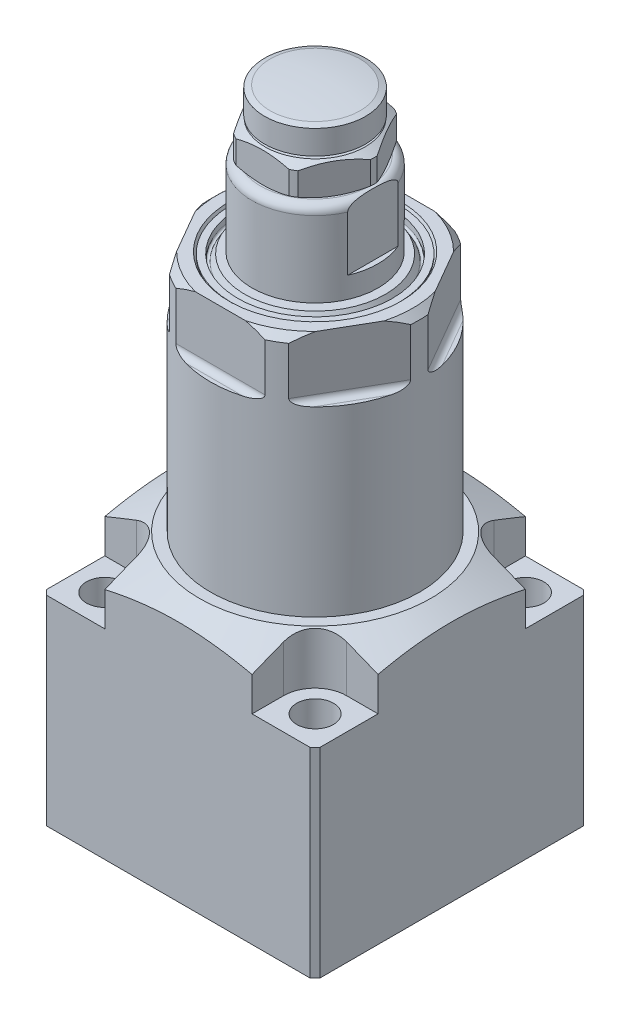
from build123d import *

# Parameters (mm, degrees)
SKETCH2_OUTSIDE_W   = 48.332
SKETCH2_OUTSIDE_H   = 48.332
CUT_EXTRUDE1_DEPTH  = 9.144
FILLET1_R           = 0.9144
SKETCH4_W           = 0.79375
SKETCH4_H           = 9.525
CUT_EXTRUDE2_DEPTH  = 11.1125
SKETCH5_W           = 4.6736
SKETCH5_H           = 6.35
SKETCH8_OUTSIDE_W   = 51.238
SKETCH8_OUTSIDE_H   = 51.238
CUT_EXTRUDE3_DEPTH  = 4.7752
SKETCH9_W           = 41.275
SKETCH9_H           = 38.1
BOSS_EXTRUDE1_DEPTH = 20.6375
CHAMFER1_SIZE       = 0.762
SKETCH10_R          = 2.7813
CUT_EXTRUDE4_DEPTH  = 41.275
SKETCH12_R          = 10.4775
CUT_EXTRUDE5_DEPTH  = 0.254
SKETCH13_R          = 4.9784
CUT_EXTRUDE6_DEPTH  = 8.89
SKETCH14_R          = 4.3688
CUT_EXTRUDE7_DEPTH  = 8.89
SKETCH15_R          = 6.4135
CUT_EXTRUDE8_DEPTH  = 1.9558
SKETCH16_R          = 4.1656
CUT_EXTRUDE9_DEPTH  = 3.9624
CUT_EXTRUDE10_DEPTH = 6.35
CUT_EXTRUDE11_DEPTH = 7.9375


with BuildPart() as part:
    # Sketch1 → Revolve1 (revolve)
    with BuildSketch(Plane.XY):
        with BuildLine():
            Line((9.4615, 0), (10.5918, 0))
            Line((10.5918, 0), (10.9728, 0.381))
            Line((10.9728, 0.381), (14.1097, 0.381))
            Line((14.1097, 0.381), (14.8717, 1.143))
            Line((14.8717, 1.143), (14.8717, 8.3058))
            Line((14.8717, 8.3058), (15.7988, 9.2329))
            Line((15.7988, 9.2329), (15.7988, 57.0992))
            Line((15.7988, 57.0992), (14.7828, 58.1152))
            Line((14.7828, 58.1152), (12.993293937, 58.1152))
            Line((12.993293937, 58.1152), (12.7, 57.6072))
            Line((12.7, 57.6072), (12.7, 57.8358))
            Line((12.7, 57.8358), (11.684, 57.8358))
            Line((11.684, 57.8358), (11.684, 56.9468))
            ThreePointArc((11.684, 56.9468), (11.495740037, 56.70145484), (11.210029547, 56.8198))
            Line((11.210029547, 56.8198), (10.623441674, 57.8358))
            Line((10.623441674, 57.8358), (0, 57.8358))
            Line((0, 57.8358), (0, 5.1308))
            Line((0, 5.1308), (2.3876, 5.1308))
            Line((2.3876, 5.1308), (2.3876, 1.3208))
            Line((2.3876, 1.3208), (8.5725, 1.3208))
            ThreePointArc((8.5725, 1.3208), (7.943882072, -0.196817928), (9.4615, 0.4318))
            Line((9.4615, 0.4318), (9.4615, 0))
        make_face()
    revolve(axis=Axis((0, 0, 0), (0, 1, 0)))

    # Sketch2 outside → Cut-Extrude1 (cut)
    with BuildSketch(Plane(origin=(0, 58.1152, 0), x_dir=(1, 0, 0), z_dir=(0, 1, 0))):
        Rectangle(SKETCH2_OUTSIDE_W, SKETCH2_OUTSIDE_H)
        Polygon((16.497783942, 0), (8.248891971, 14.2875), (-8.248891971, 14.2875), (-16.497783942, 0), (-8.248891971, -14.2875), (8.248891971, -14.2875), align=None, mode=Mode.SUBTRACT)
    extrude(amount=-CUT_EXTRUDE1_DEPTH, mode=Mode.SUBTRACT)

    # Fillet1
    fillet1_edges = [part.edges().sort_by_distance(p)[0] for p in [
        (-12.373337957, 48.9712, -7.14375),
        (0, 48.9712, -14.2875),
        (12.373337957, 48.9712, -7.14375),
        (12.373337957, 48.9712, 7.14375),
        (0, 48.9712, 14.2875),
        (-12.373337957, 48.9712, 7.14375),
    ]]
    fillet(fillet1_edges, radius=FILLET1_R)

    # Sketch9 → Boss-Extrude1 (add, symmetric)
    with BuildSketch(Plane.XY):
        with Locations((-0.0127, 2.4384)):
            Rectangle(SKETCH9_W, SKETCH9_H)
    extrude(amount=BOSS_EXTRUDE1_DEPTH, both=True)

    # Chamfer1
    chamfer1_edges = [part.edges().sort_by_distance(p)[0] for p in [
        (-20.6502, 2.4384, -20.6375),
        (20.6248, 2.4384, -20.6375),
        (-20.6502, 2.4384, 20.6375),
        (20.6248, 2.4384, 20.6375),
    ]]
    chamfer(chamfer1_edges, length=CHAMFER1_SIZE)

    # Sketch10 → Cut-Extrude4 (cut)
    with BuildSketch(Plane(origin=(0, 21.4884, 0), x_dir=(1, 0, 0), z_dir=(0, 1, 0))):
        with Locations(Location((-15.875, 15.875, 0), (0, 0, 180))):  # turned: the seam where the file's is
            Circle(SKETCH10_R)
        with Locations(Location((15.875, 15.875, 0), (0, 0, 180))):  # turned: the seam where the file's is
            Circle(SKETCH10_R)
        with Locations(Location((15.875, -15.875, 0), (0, 0, 180))):  # turned: the seam where the file's is
            Circle(SKETCH10_R)
        with Locations(Location((-15.875, -15.875, 0), (0, 0, 180))):  # turned: the seam where the file's is
            Circle(SKETCH10_R)
    extrude(amount=-CUT_EXTRUDE4_DEPTH, mode=Mode.SUBTRACT)

    # Sketch11 → Cut-Revolve1 (revolve, cut)
    with BuildSketch(Plane.XY):
        Polygon((17.4625, 21.4884), (30.1625, 21.4884), (30.1625, 15.566292741), align=None)
    revolve(axis=Axis((0, 45.350140126, 0), (0, -1, 0)), mode=Mode.SUBTRACT)

    # Sketch12 → Cut-Extrude5 (cut)
    with BuildSketch(Plane.ZY.offset(20.6502)):
        with Locations((0.0127, -7.0866)):
            Circle(SKETCH12_R)
    extrude(amount=-CUT_EXTRUDE5_DEPTH, mode=Mode.SUBTRACT)

    # Sketch13 → Cut-Extrude6 (cut)
    with BuildSketch(Plane.ZY.offset(20.3962)):
        with Locations(Location((0.0127, -7.0866, 0), (0, 0, 270))):  # turned: the seam where the file's is
            Circle(SKETCH13_R)
    extrude(amount=-CUT_EXTRUDE6_DEPTH, mode=Mode.SUBTRACT)

    # Sketch14 → Cut-Extrude7 (cut)
    with BuildSketch(Plane(origin=(0, 0, -20.6375), x_dir=(-1, 0, 0), z_dir=(0, 0, -1))):
        with Locations((-6.3246, -6.2992)):
            Circle(SKETCH14_R)
    extrude(amount=-CUT_EXTRUDE7_DEPTH, mode=Mode.SUBTRACT)

    # Sketch15 → Cut-Extrude8 (cut)
    with BuildSketch(Plane.XZ.offset(16.6116)):
        with Locations(Location((-7.9502, 8.7376, 0), (0, 0, 270))):  # turned: the seam where the file's is
            Circle(SKETCH15_R)
        with Locations(Location((9.1186, -7.9502, 0), (0, 0, 270))):  # turned: the seam where the file's is
            Circle(SKETCH15_R)
    extrude(amount=-CUT_EXTRUDE8_DEPTH, mode=Mode.SUBTRACT)

    # Sketch16 → Cut-Extrude9 (cut)
    with BuildSketch(Plane(origin=(0, -14.6558, 0), x_dir=(-1, 0, 0), z_dir=(0, -1, 0))):
        with Locations(Location((7.9502, -8.7376, 0), (0, 0, 90))):  # turned: the seam where the file's is
            Circle(SKETCH16_R)
        with Locations(Location((-9.1186, 7.9502, 0), (0, 0, 90))):  # turned: the seam where the file's is
            Circle(SKETCH16_R)
    extrude(amount=-CUT_EXTRUDE9_DEPTH, mode=Mode.SUBTRACT)

    # Sketch18 → Revolve5 (revolve)
    with BuildSketch(Plane.XY, mode=Mode.PRIVATE) as revolve5_sk:
        Polygon((-20.3962, -1.524), (-20.3962, -1.0287), (-21.4122, -0.8001), (-22.644034534, -1.5113), (-22.644034534, -7.0866), (-11.2522, -7.0866), (-11.2522, -1.524), align=None)
    revolve(revolve5_sk.sketch.rotate(Axis((-24.575209043, -7.0866, 0), (1, 0, 0)), 90), axis=Axis((-24.575209043, -7.0866, 0), (1, 0, 0)))  # turned: the seam where the file's is

    # Sketch20 → Cut-Extrude10 (cut)
    with BuildSketch(Plane.ZY.offset(22.644034534)):
        Polygon((0, -4.340184671), (2.38125, -5.715), (2.38125, -8.4582), (0, -9.833015329), (-2.38125, -8.4582), (-2.38125, -5.715), align=None)
    extrude(amount=-CUT_EXTRUDE10_DEPTH, mode=Mode.SUBTRACT)

    # Sketch21 → Cut-Extrude11 (cut)
    with BuildSketch(Plane(origin=(0, 21.4884, 0), x_dir=(1, 0, 0), z_dir=(0, 1, 0))):
        with BuildLine():
            Line((-15.875, -11.0998), (-20.6502, -11.0998))
            Line((-20.6502, -11.0998), (-20.6502, -20.6502))
            Line((-20.6502, -20.6502), (-11.0998, -20.6375))
            Line((-11.0998, -20.6375), (-11.0998, -15.875))
            ThreePointArc((-11.0998, -15.875), (-12.498423698, -12.498423698), (-15.875, -11.0998))
        make_face()
        with BuildLine():
            Line((-15.875, 11.0998), (-20.6502, 11.0998))
            Line((-20.6502, 11.0998), (-20.6502, 20.6502))
            Line((-20.6502, 20.6502), (-11.0998, 20.6375))
            Line((-11.0998, 20.6375), (-11.0998, 15.875))
            ThreePointArc((-11.0998, 15.875), (-12.498423698, 12.498423698), (-15.875, 11.0998))
        make_face()
        with BuildLine():
            Line((11.1125, 15.875), (11.1125, 20.6375))
            Line((11.1125, 20.6375), (20.6375, 20.6375))
            Line((20.6375, 20.6375), (20.6248, 11.1125))
            Line((20.6248, 11.1125), (15.875, 11.1125))
            ThreePointArc((15.875, 11.1125), (12.507403955, 12.507403955), (11.1125, 15.875))
        make_face()
        with BuildLine():
            Line((11.1252, -15.875), (11.1252, -20.6375))
            Line((11.1252, -20.6375), (20.6248, -20.6375))
            Line((20.6248, -20.6375), (20.6248, -11.1252))
            Line((20.6248, -11.1252), (15.875, -11.1252))
            ThreePointArc((15.875, -11.1252), (12.516384211, -12.516384211), (11.1252, -15.875))
        make_face()
    extrude(amount=-CUT_EXTRUDE11_DEPTH, mode=Mode.SUBTRACT)


with BuildPart() as body_2:
    # Sketch3 → Revolve2 (revolve)
    with BuildSketch(Plane.XY):
        with BuildLine():
            Line((0, 58.1152), (0, 70.8152))
            Line((0, 70.8152), (8.255, 70.8152))
            ThreePointArc((8.255, 70.8152), (9.153025612, 70.443225612), (9.525, 69.5452))
            Line((9.525, 69.5452), (9.525, 58.1152))
            Line((9.525, 58.1152), (0, 58.1152))
        make_face()
    revolve(axis=Axis((0, 43.688, 0), (0, 1, 0)))

    # Sketch4 → Cut-Extrude2 (cut, symmetric)
    with BuildSketch(Plane.XY):
        with Locations((-9.128125, 66.0527)):
            Rectangle(SKETCH4_W, SKETCH4_H)
        with Locations((9.128125, 66.0527)):
            Rectangle(SKETCH4_W, SKETCH4_H)
    extrude(amount=CUT_EXTRUDE2_DEPTH, both=True, mode=Mode.SUBTRACT)

    # Sketch5 → 7_16-14 Tapped Hole1 (revolve, cut)
    with BuildSketch(Plane(origin=(0, 70.8152, 0), x_dir=(0, 0, 1), z_dir=(1, 0, 0))):
        with Locations((2.3368, 3.175)):
            Rectangle(SKETCH5_W, SKETCH5_H)
    revolve(axis=Axis((0, 77.1652, 0), (0, -1, 0)), mode=Mode.SUBTRACT)

    # Sketch7 → Revolve3 (revolve)
    with BuildSketch(Plane.XY):
        Polygon((0, 75.5904), (7.570177285, 75.5904), (8.89, 74.8284), (8.89, 71.365126131), (7.9375, 70.8152), (0, 70.8152), align=None)
    revolve(axis=Axis((0, 0, 0), (0, -1, 0)))

    # Sketch8 outside → Cut-Extrude3 (cut)
    with BuildSketch(Plane(origin=(0, 75.5904, 0), x_dir=(1, 0, 0), z_dir=(0, 1, 0))):
        Rectangle(SKETCH8_OUTSIDE_W, SKETCH8_OUTSIDE_H)
        Polygon((9.165435523, 0), (4.582717762, 7.9375), (-4.582717762, 7.9375), (-9.165435523, 0), (-4.582717762, -7.9375), (4.582717762, -7.9375), align=None, mode=Mode.SUBTRACT)
    extrude(amount=-CUT_EXTRUDE3_DEPTH, mode=Mode.SUBTRACT)

    # Sketch17 → Revolve4 (revolve)
    with BuildSketch(Plane.XY):
        with BuildLine():
            Line((0, 75.5904), (6.960088642, 75.5904))
            Line((6.960088642, 75.5904), (7.62, 75.9714))
            Line((7.62, 75.9714), (7.62, 79.6036))
            Line((7.62, 79.6036), (6.782568883, 79.9084))
            ThreePointArc((6.782568883, 79.9084), (3.398940726, 80.250581097), (0, 80.3656))
            Line((0, 80.3656), (0, 75.5904))
        make_face()
    revolve(axis=Axis((0, 73.702224204, 0), (0, 1, 0)))


solid = Compound([part.part, body_2.part])
